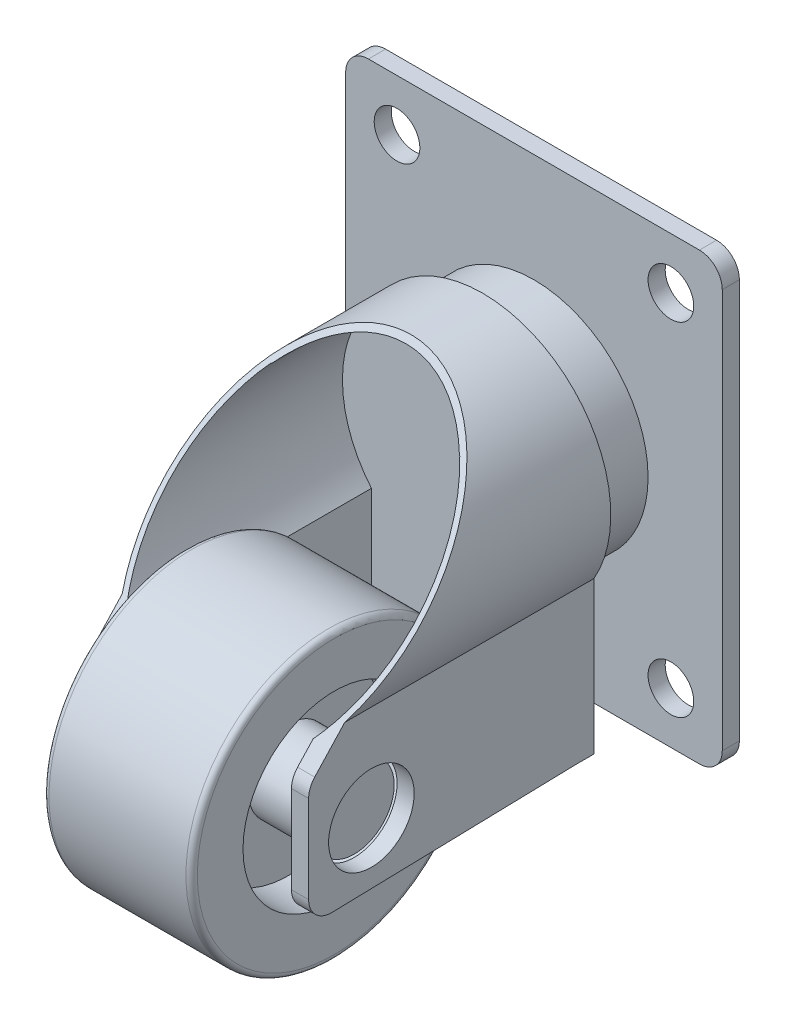
from build123d import *
from build123d.topology import SkipClean

# Parameters (mm, degrees)
SKETCH_5_R               = 3.75
EXTRUDE_2_DEPTH          = 1.5
EXTRUDE_5_DEPTH          = 21.5
CUT_EXTRUDE_1_DEPTH      = 1.6
CUT_EXTRUDE_1_DEPTH_BACK = 4.5
CUT_EXTRUDE_2_DEPTH      = 1.6
CUT_EXTRUDE_2_DEPTH_BACK = 7.5
SKETCH_22_W              = 26.817098193
SKETCH_22_H              = 16.497671188
CUT_EXTRUDE_3_DEPTH      = 19.5
CUT_EXTRUDE_4_DEPTH      = 27.5
CUT_EXTRUDE_5_DEPTH      = 15.5
EXTRUDE_6_DEPTH          = 1.5
SKETCH_30_R              = 10
EXTRUDE_7_DEPTH          = 4.49
SKETCH_31_R              = 2
EXTRUDE_8_DEPTH          = 1.5


with BuildPart() as part:
    # 草图1 → 旋转2 (revolve)
    with BuildSketch(Plane.XY, mode=Mode.PRIVATE) as revolve_2_sk:
        with BuildLine():
            Line((-23.765681953, 25.572252126), (-11.765681953, 25.572252126))
            ThreePointArc((-11.765681953, 25.572252126), (-11.412128563, 25.425805517), (-11.265681953, 25.072252126))
            Line((-11.265681953, 25.072252126), (-11.265681953, 21.072252126))
            Line((-11.265681953, 21.072252126), (-15.265681953, 21.072252126))
            Line((-15.265681953, 21.072252126), (-15.265681953, 16.572252126))
            Line((-15.265681953, 16.572252126), (-9.515681953, 16.572252126))
            Line((-9.515681953, 16.572252126), (-9.515681953, 13.072252126))
            Line((-9.515681953, 13.072252126), (-26.015681953, 13.072252126))
            Line((-26.015681953, 13.072252126), (-26.015681953, 16.572252126))
            Line((-26.015681953, 16.572252126), (-20.265681953, 16.572252126))
            Line((-20.265681953, 16.572252126), (-20.265681953, 21.072252126))
            Line((-20.265681953, 21.072252126), (-24.265681953, 21.072252126))
            Line((-24.265681953, 21.072252126), (-24.265681953, 25.072252126))
            ThreePointArc((-24.265681953, 25.072252126), (-24.119235344, 25.425805517), (-23.765681953, 25.572252126))
        make_face()
    revolve(revolve_2_sk.sketch.rotate(Axis((-9.515681953, 13.072252126, 0), (-1, 0, 0)), 90), axis=Axis((-9.515681953, 13.072252126, 0), (-1, 0, 0)))


with BuildPart() as body_2:
    # 草图5 → 凸台-拉伸2 (new body)
    with BuildSketch(Plane(origin=(-9.515681953, 0, 0), x_dir=(0, 0, -1), z_dir=(1, 0, 0))):
        with BuildLine():
            Line((10.019747389, 34.80489993), (18.005307941, 34.80489993))
            Line((18.005307941, 34.80489993), (18.005307941, 8.168731038))
            Line((18.005307941, 8.168731038), (-3.449263634, 7.624292329))
            ThreePointArc((-3.449263634, 7.624292329), (-4.896160318, 8.191609448), (-5.5, 9.623648681))
            Line((-5.5, 9.623648681), (-5.5, 17.295944941))
            ThreePointArc((-5.5, 17.295944941), (-5.361721588, 18.026693001), (-4.966007273, 18.65639438))
            Line((-4.966007273, 18.65639438), (10.019747389, 34.80489993))
        make_face()
        with Locations((0, 13.072252126)):
            Circle(SKETCH_5_R, mode=Mode.SUBTRACT)
    extrude(amount=EXTRUDE_2_DEPTH)


with BuildPart() as body_3:
    # 镜向24: mirrored copy
    add(body_2.part.mirror(Plane.ZY.offset(17.765681953)))


with BuildPart() as body_2_1:
    add(body_2.part)

    add(body_3.part)  # 凸台-拉伸5 merges body 3
    # 草图11 → 凸台-拉伸5 (add)
    with BuildSketch(Plane(origin=(0, 0, -18.005307941), x_dir=(-1, 0, 0), z_dir=(0, 0, -1))):
        with BuildLine():
            Line((8.015681953, 21.486815484), (9.076342125, 20.715560721))
            ThreePointArc((9.076342125, 20.715560721), (17.765681953, 37.789829256), (26.455021781, 20.715560721))
            Line((26.455021781, 20.715560721), (27.515681953, 21.486815484))
            ThreePointArc((27.515681953, 21.486815484), (17.765681953, 38.262970038), (8.015681953, 21.486815484))
        make_face()
    extrude(amount=-EXTRUDE_5_DEPTH)

    # 草图20 → 切除-拉伸1 (cut, two sides)
    with BuildSketch(Plane(origin=(-26.015681953, 0, 0), x_dir=(0, 0, -1), z_dir=(1, 0, 0))) as cut_extrude_1_sk:
        Polygon((-4.683045303, 20.42370573), (-4.683045303, 39.090544701), (13.996810214, 39.090544701), (-4.683045303, 18.961311485), align=None)
    extrude(amount=CUT_EXTRUDE_1_DEPTH, mode=Mode.SUBTRACT)
    extrude(cut_extrude_1_sk.sketch, amount=-CUT_EXTRUDE_1_DEPTH_BACK, mode=Mode.SUBTRACT)

    # 草图21 → 切除-拉伸2 (cut, two sides)
    with BuildSketch(Plane.ZY.offset(9.515681953)) as cut_extrude_2_sk:
        Polygon((4.577823746, 22.481995167), (4.577823746, 40.538468548), (-15.3404783, 40.538468548), (4.577823746, 19.074697226), align=None)
    extrude(amount=CUT_EXTRUDE_2_DEPTH, mode=Mode.SUBTRACT)
    extrude(cut_extrude_2_sk.sketch, amount=-CUT_EXTRUDE_2_DEPTH_BACK, mode=Mode.SUBTRACT)

    # 草图22 → 切除-拉伸3 (cut)
    with BuildSketch(Plane(origin=(0, 11.108506392, 11.970419987), x_dir=(1, 0, 0), z_dir=(0, 0.6802247196005162, 0.7330036363104886))):
        with Locations((-17.080425975, 31.663597137)):
            Rectangle(SKETCH_22_W, SKETCH_22_H)
    extrude(amount=CUT_EXTRUDE_3_DEPTH, mode=Mode.SUBTRACT)

    # 草图23 → 切除-拉伸4 (cut)
    with BuildSketch(Plane(origin=(0, 0, -18.005307941), x_dir=(-1, 0, 0), z_dir=(0, 0, -1))):
        with BuildLine():
            Line((10.094002143, 34.593281748), (9.969015318, 19.619090169))
            ThreePointArc((9.969015318, 19.619090169), (7.001201529, 27.131479376), (10.094002143, 34.593281748))
        make_face()
        with BuildLine():
            Line((26.002278311, 20.069234364), (26.015681953, 33.998161251))
            ThreePointArc((26.015681953, 33.998161251), (28.55714691, 27.031245737), (26.002278311, 20.069234364))
        make_face()
    extrude(amount=-CUT_EXTRUDE_4_DEPTH, mode=Mode.SUBTRACT)

    # 草图25 → 切除-拉伸5 (cut)
    with SkipClean():  # the faces are left unmerged after this step: merging them gives an invalid solid
        with BuildSketch(Plane(origin=(0, 0, -18.005307941), x_dir=(-1, 0, 0), z_dir=(0, 0, -1))):
            with BuildLine():
                Line((6.004810848, 32.418786574), (7.656015217, 31.911240633))
                ThreePointArc((7.656015217, 31.911240633), (18.36998363, 38.246686524), (28.340434079, 30.795705942))
                Line((28.340434079, 30.795705942), (29.745614925, 31.911240633))
                ThreePointArc((29.745614925, 31.911240633), (18.042083375, 39.97049336), (6.004810848, 32.418786574))
            make_face()
        extrude(amount=-CUT_EXTRUDE_5_DEPTH, mode=Mode.SUBTRACT)

    # 草图29 → 凸台-拉伸6 (add)
    with SkipClean():  # the faces are left unmerged after this step: merging them gives an invalid solid
        with BuildSketch(Plane(origin=(0, 0, -18.005307941), x_dir=(-1, 0, 0), z_dir=(0, 0, -1))):
            with BuildLine():
                Line((27.515681953, 21.486815484), (27.515681953, 8.168731038))
                Line((27.515681953, 8.168731038), (8.015681953, 8.168731038))
                Line((8.015681953, 8.168731038), (8.015681953, 21.486815484))
                ThreePointArc((8.015681953, 21.486815484), (17.765681953, 38.262970038), (27.515681953, 21.486815484))
            make_face()
        extrude(amount=EXTRUDE_6_DEPTH)

    # 草图30 → 凸台-拉伸7 (add)
    with SkipClean():  # the faces are left unmerged after this step: merging them gives an invalid solid
        with BuildSketch(Plane(origin=(0, 0, -19.505307941), x_dir=(-1, 0, 0), z_dir=(0, 0, -1))):
            with Locations((17.765681953, 27.041630236)):
                Circle(SKETCH_30_R)
        extrude(amount=EXTRUDE_7_DEPTH)

    # 草图31 → 凸台-拉伸8 (add)
    with SkipClean():  # the faces are left unmerged after this step: merging them gives an invalid solid
        with BuildSketch(Plane(origin=(0, 0, -23.995307941), x_dir=(-1, 0, 0), z_dir=(0, 0, -1))):
            with BuildLine():
                Line((32.265681953, 7.541630236), (3.265681953, 7.541630236))
                ThreePointArc((3.265681953, 7.541630236), (1.851468391, 8.127416674), (1.265681953, 9.541630236))
                Line((1.265681953, 9.541630236), (1.265681953, 44.541630236))
                ThreePointArc((1.265681953, 44.541630236), (1.851468391, 45.955843799), (3.265681953, 46.541630236))
                Line((3.265681953, 46.541630236), (32.265681953, 46.541630236))
                ThreePointArc((32.265681953, 46.541630236), (33.679895516, 45.955843799), (34.265681953, 44.541630236))
                Line((34.265681953, 44.541630236), (34.265681953, 9.541630236))
                ThreePointArc((34.265681953, 9.541630236), (33.679895516, 8.127416674), (32.265681953, 7.541630236))
            make_face()
            with Locations((29.765681953, 12.041630236)):
                Circle(SKETCH_31_R, mode=Mode.SUBTRACT)
            with Locations((5.765681953, 12.041630236)):
                Circle(SKETCH_31_R, mode=Mode.SUBTRACT)
            with Locations((29.765681953, 42.041630236)):
                Circle(SKETCH_31_R, mode=Mode.SUBTRACT)
            with Locations((5.765681953, 42.041630236)):
                Circle(SKETCH_31_R, mode=Mode.SUBTRACT)
        extrude(amount=EXTRUDE_8_DEPTH)


solid = Compound([part.part, body_2_1.part])
